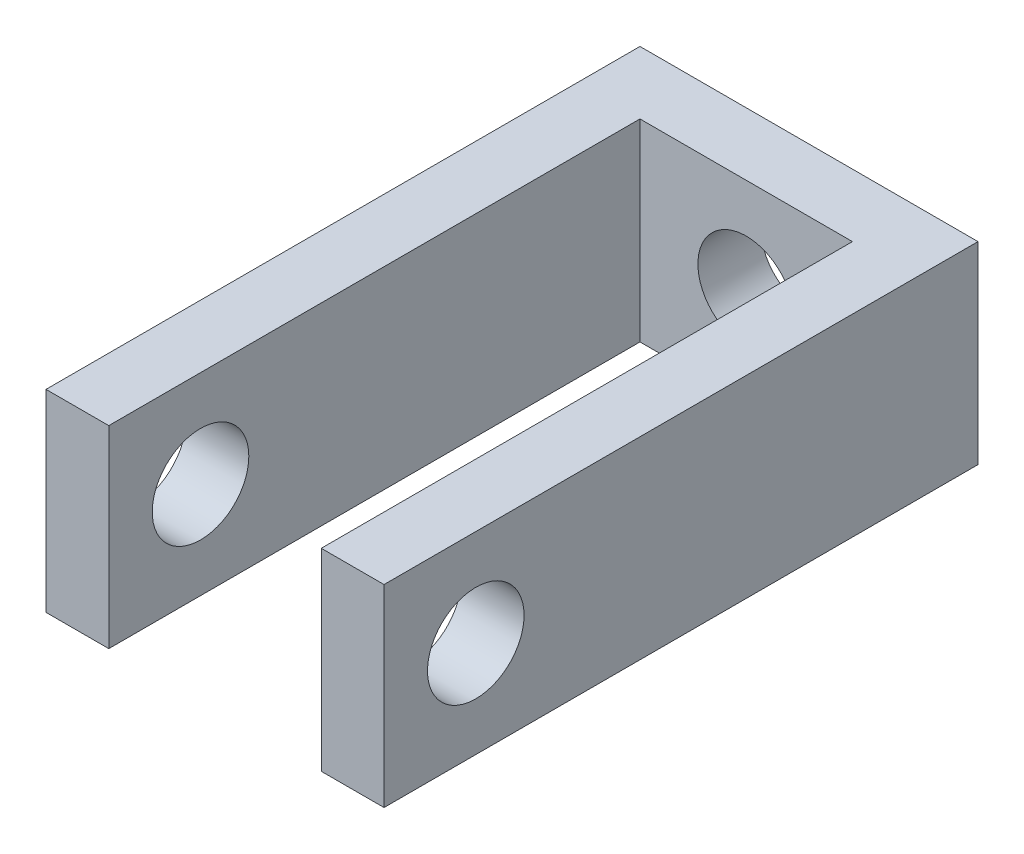
from build123d import *

# Parameters (mm, degrees)
SKETCH_1_W          = 7
SKETCH_1_H          = 4
EXTRUDE_1_DEPTH     = 1.3
SKETCH_2_W          = 1.3
SKETCH_2_H          = 4
EXTRUDE_2_DEPTH     = 11
SKETCH_3_R          = 1
CUT_EXTRUDE_1_DEPTH = 2
SKETCH_4_R          = 1
CUT_EXTRUDE_2_DEPTH = 7


with BuildPart() as part:
    # 草图1 → 凸台-拉伸1 (new body)
    with BuildSketch(Plane.XY):
        with Locations((3.5, 2)):
            Rectangle(SKETCH_1_W, SKETCH_1_H)
    extrude(amount=EXTRUDE_1_DEPTH)

    # 草图2 → 凸台-拉伸2 (add)
    with BuildSketch(Plane.XY.offset(1.3)):
        with Locations((0.65, 2)):
            Rectangle(SKETCH_2_W, SKETCH_2_H)
        with Locations((6.35, 2)):
            Rectangle(SKETCH_2_W, SKETCH_2_H)
    extrude(amount=EXTRUDE_2_DEPTH)

    # 草图3 → 切除-拉伸1 (cut)
    with BuildSketch(Plane.XY.offset(1.3)):
        with Locations((3.5, 2)):
            Circle(SKETCH_3_R)
    extrude(amount=-CUT_EXTRUDE_1_DEPTH, mode=Mode.SUBTRACT)

    # 草图4 → 切除-拉伸2 (cut)
    with BuildSketch(Plane(origin=(7, 0, 0), x_dir=(0, 0, -1), z_dir=(1, 0, 0))):
        with Locations((-10.4, 2)):
            Circle(SKETCH_4_R)
    extrude(amount=-CUT_EXTRUDE_2_DEPTH, mode=Mode.SUBTRACT)


solid = part.part
